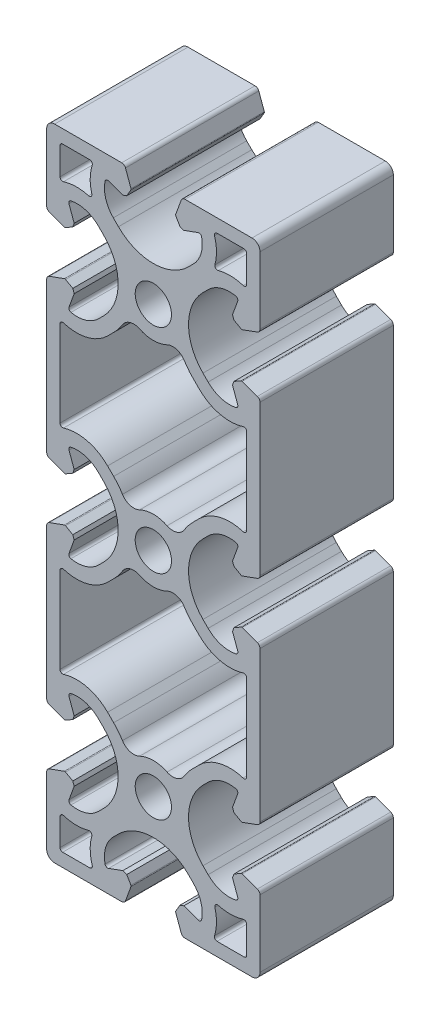
from build123d import *

# Parameters (mm, degrees)
SK_MAIN_EXTRUSION_R  = 3.4
MAIN_EXTRUSION_DEPTH = 25


with BuildPart() as part:
    # Sk Main Extrusion → Main Extrusion (new body)
    with BuildSketch(Plane.XY):
        with BuildLine():
            Line((4.190076845, -56.671180212), (5.222054351, -59.506515107))
            ThreePointArc((5.222054351, -59.506515107), (5.496641489, -59.864364033), (5.926823816, -60))
            Line((5.926823816, -60), (18.5, -60))
            ThreePointArc((18.5, -60), (19.560660172, -59.560660172), (20, -58.5))
            Line((20, -58.5), (20, -45.926823816))
            ThreePointArc((20, -45.926823816), (19.864364033, -45.496641489), (19.506515107, -45.222054351))
            Line((19.506515107, -45.222054351), (16.671180212, -44.190076845))
            ThreePointArc((16.671180212, -44.190076845), (16.563886241, -44.175951325), (16.460675177, -44.208493649))
            Line((16.460675177, -44.208493649), (15.111296024, -44.987558066))
            Line((15.111296024, -44.987558066), (14.845251581, -45.718509166))
            Line((14.845251581, -45.718509166), (15.81984631, -48.396186179))
            ThreePointArc((15.81984631, -48.396186179), (15.786489799, -48.811074612), (15.450654467, -49.056960151))
            ThreePointArc((15.450654467, -49.056960151), (12.665882372, -48.933433013), (10.272684887, -47.504160339))
            Line((10.272684887, -47.504160339), (9.309262274, -46.540737726))
            ThreePointArc((9.309262274, -46.540737726), (6.6, -40), (9.309262274, -33.459262274))
            Line((9.309262274, -33.459262274), (10.272684887, -32.495839661))
            ThreePointArc((10.272684887, -32.495839661), (12.665882372, -31.066566987), (15.450654467, -30.943039849))
            ThreePointArc((15.450654467, -30.943039849), (15.786489799, -31.188925388), (15.81984631, -31.603813821))
            Line((15.81984631, -31.603813821), (14.845251581, -34.281490834))
            Line((14.845251581, -34.281490834), (15.111296024, -35.012441934))
            Line((15.111296024, -35.012441934), (16.460675177, -35.791506351))
            ThreePointArc((16.460675177, -35.791506351), (16.563886241, -35.824048675), (16.671180212, -35.809923155))
            Line((16.671180212, -35.809923155), (19.506515107, -34.777945649))
            ThreePointArc((19.506515107, -34.777945649), (19.864364033, -34.503358511), (20, -34.073176184))
            Line((20, -34.073176184), (20, -5.926823816))
            ThreePointArc((20, -5.926823816), (19.864364033, -5.496641489), (19.506515107, -5.222054351))
            Line((19.506515107, -5.222054351), (16.671180212, -4.190076845))
            ThreePointArc((16.671180212, -4.190076845), (16.563886241, -4.175951325), (16.460675177, -4.208493649))
            Line((16.460675177, -4.208493649), (15.111296024, -4.987558066))
            Line((15.111296024, -4.987558066), (14.845251581, -5.718509166))
            Line((14.845251581, -5.718509166), (15.81984631, -8.396186179))
            ThreePointArc((15.81984631, -8.396186179), (15.786489799, -8.811074612), (15.450654467, -9.056960151))
            ThreePointArc((15.450654467, -9.056960151), (12.665882372, -8.933433013), (10.272684887, -7.504160339))
            Line((10.272684887, -7.504160339), (9.309262274, -6.540737726))
            ThreePointArc((9.309262274, -6.540737726), (6.6, 0), (9.309262274, 6.540737726))
            Line((9.309262274, 6.540737726), (10.272684887, 7.504160339))
            ThreePointArc((10.272684887, 7.504160339), (12.665882372, 8.933433013), (15.450654467, 9.056960151))
            ThreePointArc((15.450654467, 9.056960151), (15.786489799, 8.811074612), (15.81984631, 8.396186179))
            Line((15.81984631, 8.396186179), (14.845251581, 5.718509166))
            Line((14.845251581, 5.718509166), (15.111296024, 4.987558066))
            Line((15.111296024, 4.987558066), (16.460675177, 4.208493649))
            ThreePointArc((16.460675177, 4.208493649), (16.563886241, 4.175951325), (16.671180212, 4.190076845))
            Line((16.671180212, 4.190076845), (19.506515107, 5.222054351))
            ThreePointArc((19.506515107, 5.222054351), (19.864364033, 5.496641489), (20, 5.926823816))
            Line((20, 5.926823816), (20, 34.073176184))
            ThreePointArc((20, 34.073176184), (19.864364033, 34.503358511), (19.506515107, 34.777945649))
            Line((19.506515107, 34.777945649), (16.671180212, 35.809923155))
            ThreePointArc((16.671180212, 35.809923155), (16.563886241, 35.824048675), (16.460675177, 35.791506351))
            Line((16.460675177, 35.791506351), (15.111296024, 35.012441934))
            Line((15.111296024, 35.012441934), (14.845251581, 34.281490834))
            Line((14.845251581, 34.281490834), (15.81984631, 31.603813821))
            ThreePointArc((15.81984631, 31.603813821), (15.786489799, 31.188925388), (15.450654467, 30.943039849))
            ThreePointArc((15.450654467, 30.943039849), (12.665882372, 31.066566987), (10.272684887, 32.495839661))
            Line((10.272684887, 32.495839661), (9.309262274, 33.459262274))
            ThreePointArc((9.309262274, 33.459262274), (6.6, 40), (9.309262274, 46.540737726))
            Line((9.309262274, 46.540737726), (10.272684887, 47.504160339))
            ThreePointArc((10.272684887, 47.504160339), (12.665882372, 48.933433013), (15.450654467, 49.056960151))
            ThreePointArc((15.450654467, 49.056960151), (15.786489799, 48.811074612), (15.81984631, 48.396186179))
            Line((15.81984631, 48.396186179), (14.845251581, 45.718509166))
            Line((14.845251581, 45.718509166), (15.111296024, 44.987558066))
            Line((15.111296024, 44.987558066), (16.460675177, 44.208493649))
            ThreePointArc((16.460675177, 44.208493649), (16.563886241, 44.175951325), (16.671180212, 44.190076845))
            Line((16.671180212, 44.190076845), (19.506515107, 45.222054351))
            ThreePointArc((19.506515107, 45.222054351), (19.864364033, 45.496641489), (20, 45.926823816))
            Line((20, 45.926823816), (20, 58.5))
            ThreePointArc((20, 58.5), (19.560660172, 59.560660172), (18.5, 60))
            Line((18.5, 60), (5.926823816, 60))
            ThreePointArc((5.926823816, 60), (5.496641489, 59.864364033), (5.222054351, 59.506515108))
            Line((5.222054351, 59.506515108), (4.190076845, 56.671180212))
            ThreePointArc((4.190076845, 56.671180212), (4.175951325, 56.563886241), (4.208493649, 56.460675177))
            Line((4.208493649, 56.460675177), (4.987558066, 55.111296024))
            Line((4.987558066, 55.111296024), (5.718509166, 54.845251581))
            Line((5.718509166, 54.845251581), (8.396186179, 55.81984631))
            ThreePointArc((8.396186179, 55.81984631), (8.811074612, 55.786489799), (9.056960151, 55.450654467))
            ThreePointArc((9.056960151, 55.450654467), (8.933433013, 52.665882372), (7.504160339, 50.272684887))
            Line((7.504160339, 50.272684887), (6.540737726, 49.309262274))
            ThreePointArc((6.540737726, 49.309262274), (0, 46.6), (-6.540737726, 49.309262274))
            Line((-6.540737726, 49.309262274), (-7.504160339, 50.272684887))
            ThreePointArc((-7.504160339, 50.272684887), (-8.933433013, 52.665882372), (-9.056960151, 55.450654467))
            ThreePointArc((-9.056960151, 55.450654467), (-8.811074612, 55.786489799), (-8.396186179, 55.81984631))
            Line((-8.396186179, 55.81984631), (-5.718509166, 54.845251581))
            Line((-5.718509166, 54.845251581), (-4.987558066, 55.111296024))
            Line((-4.987558066, 55.111296024), (-4.208493649, 56.460675177))
            ThreePointArc((-4.208493649, 56.460675177), (-4.175951325, 56.563886241), (-4.190076845, 56.671180212))
            Line((-4.190076845, 56.671180212), (-5.222054351, 59.506515108))
            ThreePointArc((-5.222054351, 59.506515108), (-5.496641489, 59.864364033), (-5.926823816, 60))
            Line((-5.926823816, 60), (-18.5, 60))
            ThreePointArc((-18.5, 60), (-19.560660172, 59.560660172), (-20, 58.5))
            Line((-20, 58.5), (-20, 45.926823816))
            ThreePointArc((-20, 45.926823816), (-19.864364033, 45.496641489), (-19.506515107, 45.222054351))
            Line((-19.506515107, 45.222054351), (-16.671180212, 44.190076845))
            ThreePointArc((-16.671180212, 44.190076845), (-16.563886241, 44.175951325), (-16.460675177, 44.208493649))
            Line((-16.460675177, 44.208493649), (-15.111296024, 44.987558066))
            Line((-15.111296024, 44.987558066), (-14.845251581, 45.718509166))
            Line((-14.845251581, 45.718509166), (-15.81984631, 48.396186179))
            ThreePointArc((-15.81984631, 48.396186179), (-15.786489799, 48.811074612), (-15.450654467, 49.056960151))
            ThreePointArc((-15.450654467, 49.056960151), (-12.665882372, 48.933433013), (-10.272684887, 47.504160339))
            Line((-10.272684887, 47.504160339), (-9.309262274, 46.540737726))
            ThreePointArc((-9.309262274, 46.540737726), (-6.6, 40), (-9.309262274, 33.459262274))
            Line((-9.309262274, 33.459262274), (-10.272684887, 32.495839661))
            ThreePointArc((-10.272684887, 32.495839661), (-12.665882372, 31.066566987), (-15.450654467, 30.943039849))
            ThreePointArc((-15.450654467, 30.943039849), (-15.786489799, 31.188925388), (-15.81984631, 31.603813821))
            Line((-15.81984631, 31.603813821), (-14.845251581, 34.281490834))
            Line((-14.845251581, 34.281490834), (-15.111296024, 35.012441934))
            Line((-15.111296024, 35.012441934), (-16.460675177, 35.791506351))
            ThreePointArc((-16.460675177, 35.791506351), (-16.563886241, 35.824048675), (-16.671180212, 35.809923155))
            Line((-16.671180212, 35.809923155), (-19.506515107, 34.777945649))
            ThreePointArc((-19.506515107, 34.777945649), (-19.864364033, 34.503358511), (-20, 34.073176184))
            Line((-20, 34.073176184), (-20, 5.926823816))
            ThreePointArc((-20, 5.926823816), (-19.864364033, 5.496641489), (-19.506515107, 5.222054351))
            Line((-19.506515107, 5.222054351), (-16.671180212, 4.190076845))
            ThreePointArc((-16.671180212, 4.190076845), (-16.563886241, 4.175951325), (-16.460675177, 4.208493649))
            Line((-16.460675177, 4.208493649), (-15.111296024, 4.987558066))
            Line((-15.111296024, 4.987558066), (-14.845251581, 5.718509166))
            Line((-14.845251581, 5.718509166), (-15.81984631, 8.396186179))
            ThreePointArc((-15.81984631, 8.396186179), (-15.786489799, 8.811074612), (-15.450654467, 9.056960151))
            ThreePointArc((-15.450654467, 9.056960151), (-12.665882372, 8.933433013), (-10.272684887, 7.504160339))
            Line((-10.272684887, 7.504160339), (-9.309262274, 6.540737726))
            ThreePointArc((-9.309262274, 6.540737726), (-6.6, 0), (-9.309262274, -6.540737726))
            Line((-9.309262274, -6.540737726), (-10.272684887, -7.504160339))
            ThreePointArc((-10.272684887, -7.504160339), (-12.665882372, -8.933433013), (-15.450654467, -9.056960151))
            ThreePointArc((-15.450654467, -9.056960151), (-15.786489799, -8.811074612), (-15.81984631, -8.396186179))
            Line((-15.81984631, -8.396186179), (-14.845251581, -5.718509166))
            Line((-14.845251581, -5.718509166), (-15.111296024, -4.987558066))
            Line((-15.111296024, -4.987558066), (-16.460675177, -4.208493649))
            ThreePointArc((-16.460675177, -4.208493649), (-16.563886241, -4.175951325), (-16.671180212, -4.190076845))
            Line((-16.671180212, -4.190076845), (-19.506515107, -5.222054351))
            ThreePointArc((-19.506515107, -5.222054351), (-19.864364033, -5.496641489), (-20, -5.926823816))
            Line((-20, -5.926823816), (-20, -34.073176184))
            ThreePointArc((-20, -34.073176184), (-19.864364033, -34.503358511), (-19.506515107, -34.777945649))
            Line((-19.506515107, -34.777945649), (-16.671180212, -35.809923155))
            ThreePointArc((-16.671180212, -35.809923155), (-16.563886241, -35.824048675), (-16.460675177, -35.791506351))
            Line((-16.460675177, -35.791506351), (-15.111296024, -35.012441934))
            Line((-15.111296024, -35.012441934), (-14.845251581, -34.281490834))
            Line((-14.845251581, -34.281490834), (-15.81984631, -31.603813821))
            ThreePointArc((-15.81984631, -31.603813821), (-15.786489799, -31.188925388), (-15.450654467, -30.943039849))
            ThreePointArc((-15.450654467, -30.943039849), (-12.665882372, -31.066566987), (-10.272684887, -32.495839661))
            Line((-10.272684887, -32.495839661), (-9.309262274, -33.459262274))
            ThreePointArc((-9.309262274, -33.459262274), (-6.6, -40), (-9.309262274, -46.540737726))
            Line((-9.309262274, -46.540737726), (-10.272684887, -47.504160339))
            ThreePointArc((-10.272684887, -47.504160339), (-12.665882372, -48.933433013), (-15.450654467, -49.056960151))
            ThreePointArc((-15.450654467, -49.056960151), (-15.786489799, -48.811074612), (-15.81984631, -48.396186179))
            Line((-15.81984631, -48.396186179), (-14.845251581, -45.718509166))
            Line((-14.845251581, -45.718509166), (-15.111296024, -44.987558066))
            Line((-15.111296024, -44.987558066), (-16.460675177, -44.208493649))
            ThreePointArc((-16.460675177, -44.208493649), (-16.563886241, -44.175951325), (-16.671180212, -44.190076845))
            Line((-16.671180212, -44.190076845), (-19.506515107, -45.222054351))
            ThreePointArc((-19.506515107, -45.222054351), (-19.864364033, -45.496641489), (-20, -45.926823816))
            Line((-20, -45.926823816), (-20, -58.5))
            ThreePointArc((-20, -58.5), (-19.560660172, -59.560660172), (-18.5, -60))
            Line((-18.5, -60), (-5.926823816, -60))
            ThreePointArc((-5.926823816, -60), (-5.496641489, -59.864364033), (-5.222054351, -59.506515107))
            Line((-5.222054351, -59.506515107), (-4.190076845, -56.671180212))
            ThreePointArc((-4.190076845, -56.671180212), (-4.175951325, -56.563886241), (-4.208493649, -56.460675177))
            Line((-4.208493649, -56.460675177), (-4.987558066, -55.111296024))
            Line((-4.987558066, -55.111296024), (-5.718509166, -54.845251581))
            Line((-5.718509166, -54.845251581), (-8.396186179, -55.81984631))
            ThreePointArc((-8.396186179, -55.81984631), (-8.811074612, -55.786489799), (-9.056960151, -55.450654467))
            ThreePointArc((-9.056960151, -55.450654467), (-8.933433013, -52.665882372), (-7.504160339, -50.272684887))
            Line((-7.504160339, -50.272684887), (-6.540737726, -49.309262274))
            ThreePointArc((-6.540737726, -49.309262274), (0, -46.6), (6.540737726, -49.309262274))
            Line((6.540737726, -49.309262274), (7.504160339, -50.272684887))
            ThreePointArc((7.504160339, -50.272684887), (8.933433013, -52.665882372), (9.056960151, -55.450654467))
            ThreePointArc((9.056960151, -55.450654467), (8.811074612, -55.786489799), (8.396186179, -55.81984631))
            Line((8.396186179, -55.81984631), (5.718509166, -54.845251581))
            Line((5.718509166, -54.845251581), (4.987558066, -55.111296024))
            Line((4.987558066, -55.111296024), (4.208493649, -56.460675177))
            ThreePointArc((4.208493649, -56.460675177), (4.175951325, -56.563886241), (4.190076845, -56.671180212))
        make_face()
        with Locations((0, -40)):
            Circle(SK_MAIN_EXTRUSION_R, mode=Mode.SUBTRACT)
        Circle(SK_MAIN_EXTRUSION_R, mode=Mode.SUBTRACT)
        with Locations((0, 40)):
            Circle(SK_MAIN_EXTRUSION_R, mode=Mode.SUBTRACT)
        with BuildLine():
            Line((17.5, 51.940719521), (17.5, 57))
            ThreePointArc((17.5, 57), (17.353553391, 57.353553391), (17, 57.5))
            Line((17, 57.5), (11.940719521, 57.5))
            ThreePointArc((11.940719521, 57.5), (11.537349181, 57.295452819), (11.464011904, 56.849169473))
            ThreePointArc((11.464011904, 56.849169473), (11.844928721, 54.508523804), (11.540116235, 52.156756572))
            ThreePointArc((11.540116235, 52.156756572), (11.66791097, 51.66791097), (12.156756572, 51.540116235))
            ThreePointArc((12.156756572, 51.540116235), (14.508523804, 51.844928721), (16.849169473, 51.464011904))
            ThreePointArc((16.849169473, 51.464011904), (17.295452819, 51.537349181), (17.5, 51.940719521))
        make_face(mode=Mode.SUBTRACT)
        with BuildLine():
            Line((-17.5, 57), (-17.5, 51.940719521))
            ThreePointArc((-17.5, 51.940719521), (-17.295452819, 51.537349181), (-16.849169473, 51.464011904))
            ThreePointArc((-16.849169473, 51.464011904), (-14.508523804, 51.844928721), (-12.156756572, 51.540116235))
            ThreePointArc((-12.156756572, 51.540116235), (-11.66791097, 51.66791097), (-11.540116235, 52.156756572))
            ThreePointArc((-11.540116235, 52.156756572), (-11.844928721, 54.508523804), (-11.464011904, 56.849169473))
            ThreePointArc((-11.464011904, 56.849169473), (-11.537349181, 57.295452819), (-11.940719521, 57.5))
            Line((-11.940719521, 57.5), (-17, 57.5))
            ThreePointArc((-17, 57.5), (-17.353553391, 57.353553391), (-17.5, 57))
        make_face(mode=Mode.SUBTRACT)
        with BuildLine():
            Line((-17.5, -51.940719521), (-17.5, -57))
            ThreePointArc((-17.5, -57), (-17.353553391, -57.353553391), (-17, -57.5))
            Line((-17, -57.5), (-11.940719521, -57.5))
            ThreePointArc((-11.940719521, -57.5), (-11.537349181, -57.295452819), (-11.464011904, -56.849169473))
            ThreePointArc((-11.464011904, -56.849169473), (-11.844928721, -54.508523804), (-11.540116235, -52.156756572))
            ThreePointArc((-11.540116235, -52.156756572), (-11.66791097, -51.66791097), (-12.156756572, -51.540116235))
            ThreePointArc((-12.156756572, -51.540116235), (-14.508523804, -51.844928721), (-16.849169473, -51.464011904))
            ThreePointArc((-16.849169473, -51.464011904), (-17.295452819, -51.537349181), (-17.5, -51.940719521))
        make_face(mode=Mode.SUBTRACT)
        with BuildLine():
            Line((11.940719521, -57.5), (17, -57.5))
            ThreePointArc((17, -57.5), (17.353553391, -57.353553391), (17.5, -57))
            Line((17.5, -57), (17.5, -51.940719521))
            ThreePointArc((17.5, -51.940719521), (17.295452819, -51.537349181), (16.849169473, -51.464011904))
            ThreePointArc((16.849169473, -51.464011904), (14.508523804, -51.844928721), (12.156756572, -51.540116235))
            ThreePointArc((12.156756572, -51.540116235), (11.66791097, -51.66791097), (11.540116235, -52.156756572))
            ThreePointArc((11.540116235, -52.156756572), (11.844928721, -54.508523804), (11.464011904, -56.849169473))
            ThreePointArc((11.464011904, -56.849169473), (11.537349181, -57.295452819), (11.940719521, -57.5))
        make_face(mode=Mode.SUBTRACT)
        with BuildLine():
            Line((17.5, 11.940719521), (17.5, 28.059280479))
            ThreePointArc((17.5, 28.059280479), (17.295452819, 28.462650819), (16.849169473, 28.535988096))
            ThreePointArc((16.849169473, 28.535988096), (12.430514315, 28.388012807), (8.577273231, 30.555717411))
            Line((8.577273231, 30.555717411), (7.441495321, 31.691495321))
            ThreePointArc((7.441495321, 31.691495321), (6.555931161, 32.683470892), (5.788120301, 33.769153119))
            ThreePointArc((5.788120301, 33.769153119), (4.359333373, 34.846116179), (2.576734694, 34.692416904))
            ThreePointArc((2.576734694, 34.692416904), (0, 34.1), (-2.576734694, 34.692416904))
            ThreePointArc((-2.576734694, 34.692416904), (-4.359333373, 34.846116179), (-5.788120301, 33.769153119))
            ThreePointArc((-5.788120301, 33.769153119), (-6.555931161, 32.683470892), (-7.441495321, 31.691495321))
            Line((-7.441495321, 31.691495321), (-8.577273231, 30.555717411))
            ThreePointArc((-8.577273231, 30.555717411), (-12.430514315, 28.388012807), (-16.849169473, 28.535988096))
            ThreePointArc((-16.849169473, 28.535988096), (-17.295452819, 28.462650819), (-17.5, 28.059280479))
            Line((-17.5, 28.059280479), (-17.5, 11.940719521))
            ThreePointArc((-17.5, 11.940719521), (-17.295452819, 11.537349181), (-16.849169473, 11.464011904))
            ThreePointArc((-16.849169473, 11.464011904), (-12.430514315, 11.611987193), (-8.577273231, 9.444282589))
            Line((-8.577273231, 9.444282589), (-7.441495321, 8.308504679))
            ThreePointArc((-7.441495321, 8.308504679), (-6.555931161, 7.316529108), (-5.788120301, 6.230846881))
            ThreePointArc((-5.788120301, 6.230846881), (-4.359333373, 5.153883821), (-2.576734694, 5.307583096))
            ThreePointArc((-2.576734694, 5.307583096), (0, 5.9), (2.576734694, 5.307583096))
            ThreePointArc((2.576734694, 5.307583096), (4.359333373, 5.153883821), (5.788120301, 6.230846881))
            ThreePointArc((5.788120301, 6.230846881), (6.555931161, 7.316529108), (7.441495321, 8.308504679))
            Line((7.441495321, 8.308504679), (8.577273231, 9.444282589))
            ThreePointArc((8.577273231, 9.444282589), (12.430514315, 11.611987193), (16.849169473, 11.464011904))
            ThreePointArc((16.849169473, 11.464011904), (17.295452819, 11.537349181), (17.5, 11.940719521))
        make_face(mode=Mode.SUBTRACT)
        with BuildLine():
            Line((-7.441495321, -8.308504679), (-8.577273231, -9.444282589))
            ThreePointArc((-8.577273231, -9.444282589), (-12.430514315, -11.611987193), (-16.849169473, -11.464011904))
            ThreePointArc((-16.849169473, -11.464011904), (-17.295452819, -11.537349181), (-17.5, -11.940719521))
            Line((-17.5, -11.940719521), (-17.5, -28.059280479))
            ThreePointArc((-17.5, -28.059280479), (-17.295452819, -28.462650819), (-16.849169473, -28.535988096))
            ThreePointArc((-16.849169473, -28.535988096), (-12.430514315, -28.388012807), (-8.577273231, -30.555717411))
            Line((-8.577273231, -30.555717411), (-7.441495321, -31.691495321))
            ThreePointArc((-7.441495321, -31.691495321), (-6.555931161, -32.683470892), (-5.788120301, -33.769153119))
            ThreePointArc((-5.788120301, -33.769153119), (-4.359333373, -34.846116179), (-2.576734694, -34.692416904))
            ThreePointArc((-2.576734694, -34.692416904), (0, -34.1), (2.576734694, -34.692416904))
            ThreePointArc((2.576734694, -34.692416904), (4.359333373, -34.846116179), (5.788120301, -33.769153119))
            ThreePointArc((5.788120301, -33.769153119), (6.555931161, -32.683470892), (7.441495321, -31.691495321))
            Line((7.441495321, -31.691495321), (8.577273231, -30.555717411))
            ThreePointArc((8.577273231, -30.555717411), (12.430514315, -28.388012807), (16.849169473, -28.535988096))
            ThreePointArc((16.849169473, -28.535988096), (17.295452819, -28.462650819), (17.5, -28.059280479))
            Line((17.5, -28.059280479), (17.5, -11.940719521))
            ThreePointArc((17.5, -11.940719521), (17.295452819, -11.537349181), (16.849169473, -11.464011904))
            ThreePointArc((16.849169473, -11.464011904), (12.430514315, -11.611987193), (8.577273231, -9.444282589))
            Line((8.577273231, -9.444282589), (7.441495321, -8.308504679))
            ThreePointArc((7.441495321, -8.308504679), (6.555931161, -7.316529108), (5.788120301, -6.230846881))
            ThreePointArc((5.788120301, -6.230846881), (4.359333373, -5.153883821), (2.576734694, -5.307583096))
            ThreePointArc((2.576734694, -5.307583096), (0, -5.9), (-2.576734694, -5.307583096))
            ThreePointArc((-2.576734694, -5.307583096), (-4.359333373, -5.153883821), (-5.788120301, -6.230846881))
            ThreePointArc((-5.788120301, -6.230846881), (-6.555931161, -7.316529108), (-7.441495321, -8.308504679))
        make_face(mode=Mode.SUBTRACT)
    extrude(amount=-MAIN_EXTRUSION_DEPTH)


solid = part.part
